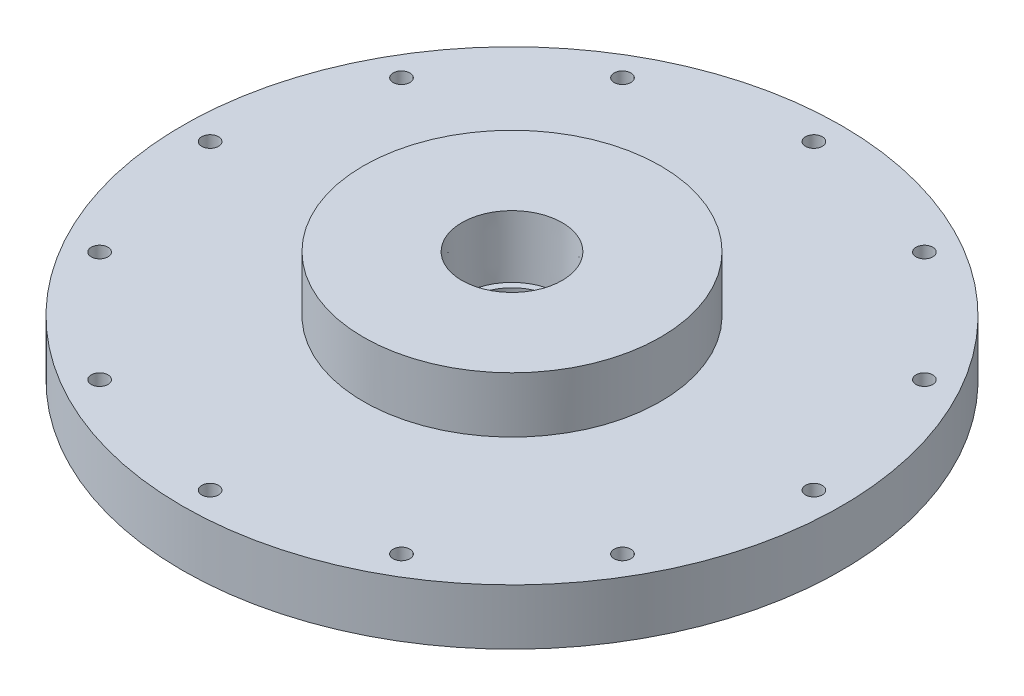
from build123d import *

# Parameters (mm, degrees)
SKETCH2_R           = 25.4
BASE_CYLINDER_DEPTH = 19.05
SKETCH3_R           = 56.35625
AFT_FLANGE_DEPTH    = 9.525
BOLT_CIRCLE_D       = 2.8702
BOLT_CIRCLE_DEPTH   = 9.525


with BuildPart() as part:
    # Sketch2 → Base Cylinder (new body)
    with BuildSketch(Plane(origin=(0, 0, 0), x_dir=(1, 0, 0), z_dir=(0, 1, 0))):
        Circle(SKETCH2_R)
    extrude(amount=BASE_CYLINDER_DEPTH)

    # Sketch3 → Aft Flange (add)
    with BuildSketch(Plane.XZ):
        Circle(SKETCH3_R)
    extrude(amount=-AFT_FLANGE_DEPTH)

    # Bolt Circle
    with Locations(Plane(origin=(0, 0, 0), x_dir=(-1, 0, 0), z_dir=(0, -1, 0))):
        with Locations((-25.81275, -44.708994483), (-44.708994483, -25.81275), (-51.6255, 0), (-44.708994483, 25.81275), (-25.81275, 44.708994483), (0, 51.6255), (25.81275, 44.708994483), (44.708994483, 25.81275), (51.6255, 0), (44.708994483, -25.81275), (25.81275, -44.708994483), (0, -51.6255)):
            Hole(BOLT_CIRCLE_D / 2, depth=BOLT_CIRCLE_DEPTH)

    # Sketch17 → 3/8 NPT Tapped Hole1 (revolve, cut)
    with BuildSketch(Plane(origin=(0, 19.05, 0), x_dir=(0, 0, 1), z_dir=(1, 0, 0))):
        Polygon((0, 0), (0, 21.814582582), (7.1374, 17.526), (7.1374, 10.414), (8.263205494, 10.414), (8.5750146, 0), align=None)
    revolve(axis=Axis((0, 25.4, 0), (0, -1, 0)), mode=Mode.SUBTRACT)


solid = part.part
